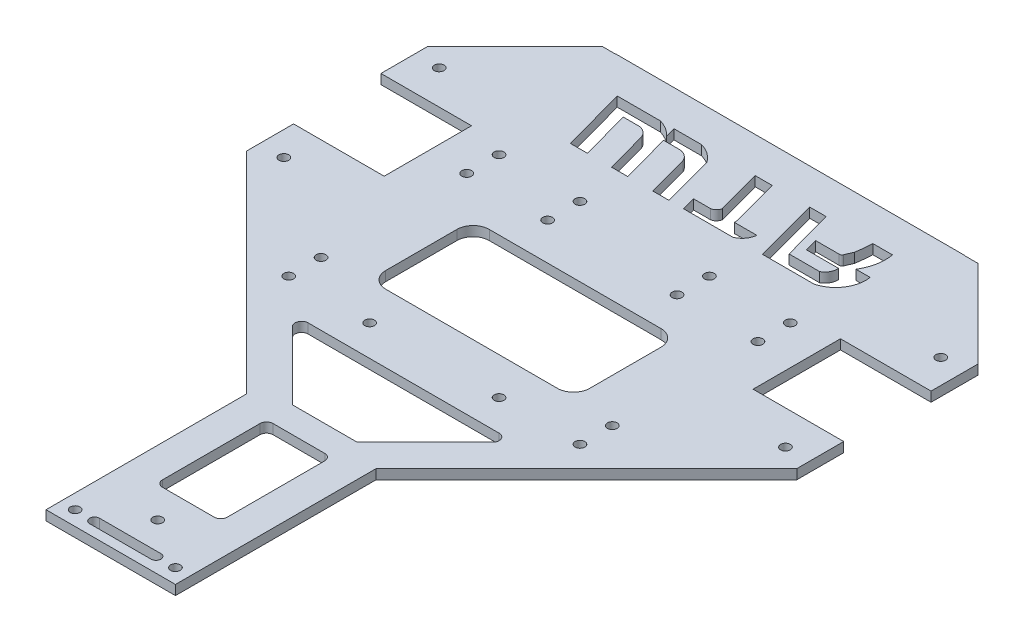
from build123d import *

# Parameters (mm, degrees)
SKETCH_1_R          = 1.5
EXTRUDE_1_DEPTH     = 3
SKETCH_2_R          = 1.5
EXTRUDE_2_DEPTH     = 3
EXTRUDE_6_DEPTH     = 3
CUT_EXTRUDE_1_DEPTH = 3
SKETCH_5_R          = 1.5
CUT_EXTRUDE_2_DEPTH = 3
SKETCH_6_R          = 1.5
CUT_EXTRUDE_5_DEPTH = 3
CUT_EXTRUDE_7_DEPTH = 3
CUT_EXTRUDE_9_DEPTH = 3


with BuildPart() as part:
    # 草图1 → 凸台-拉伸1 (new body)
    with BuildSketch(Plane(origin=(0, 0, 0), x_dir=(1, 0, 0), z_dir=(0, 1, 0))):
        Polygon((58, -55), (85, -28), (85, -13.5), (57, -13.5), (57, 13.5), (85, 13.5), (85, 24), (54, 55), (-54, 55), (-85, 24), (-85, 13.5), (-57, 13.5), (-57, -13.5), (-85, -13.5), (-85, -28), (-58, -55), align=None)
        with Locations((77.5, 24)):
            Circle(SKETCH_1_R, mode=Mode.SUBTRACT)
        with Locations((-77.5, 24)):
            Circle(SKETCH_1_R, mode=Mode.SUBTRACT)
        with Locations((-77.5, -24)):
            Circle(SKETCH_1_R, mode=Mode.SUBTRACT)
        with Locations((77.5, -24)):
            Circle(SKETCH_1_R, mode=Mode.SUBTRACT)
    extrude(amount=EXTRUDE_1_DEPTH)

    # 草图2 → 凸台-拉伸2 (add)
    with BuildSketch(Plane(origin=(0, 3, 0), x_dir=(1, 0, 0), z_dir=(0, 1, 0))):
        Polygon((57, 13.5), (85, 13.5), (85, 24), (54.078462186, 54.921537814), (-54.078462186, 54.921537814), (-85, 24), (-85, 13.5), (-57, 13.5), align=None)
        with Locations((-77.5, 24)):
            Circle(SKETCH_2_R, mode=Mode.SUBTRACT)
        with Locations((77.5, 24)):
            Circle(SKETCH_2_R, mode=Mode.SUBTRACT)
        Polygon((-85, 28), (-85, 24), (-54.078462186, 54.921537814), (-58.078462186, 54.921537814), align=None)
        Polygon((54.078462186, 54.921537814), (85, 24), (85, 28), (58.078462186, 54.921537814), align=None)
    extrude(amount=-EXTRUDE_2_DEPTH)

    # 草图3 → 凸台-拉伸6 (add)
    with BuildSketch(Plane.XZ):
        Polygon((-20, 93), (-20, 87.75862069), (20, 122.24137931), (20, 155), (-20, 155), align=None)
        Polygon((20, 122.24137931), (-20, 87.75862069), (-20, 55), (0, 55), (20, 55), (20, 93), align=None)
        Polygon((58, 55), (20, 93), (20, 55), align=None)
        Polygon((-20, 87.75862069), (-58, 55), (-20, 55), align=None)
        Polygon((-20, 93), (-58, 55), (-20, 87.75862069), align=None)
    extrude(amount=-EXTRUDE_6_DEPTH)

    # 草图4 → 切除-拉伸1 (cut)
    with BuildSketch(Plane.XZ):
        with BuildLine():
            Line((37.877062405, -32.043326777), (27.967198456, -32.043326777))
            Line((27.967198456, -32.043326777), (26.920470281, -35.937088984))
            Line((26.920470281, -35.937088984), (34.10030845, -35.937088984))
            ThreePointArc((34.10030845, -35.937088984), (34.626114104, -36.053786172), (34.982522159, -36.457596916))
            Line((34.982522159, -36.457596916), (36.01321058, -38.838842579))
            ThreePointArc((36.01321058, -38.838842579), (36.340515961, -41.403679155), (36.509138095, -43.983811332))
            Line((36.509138095, -43.983811332), (42.601961842, -43.983811332))
            ThreePointArc((42.601961842, -43.983811332), (42.5762659, -39.074399956), (40.794165727, -34.499785293))
            Line((40.794165727, -34.499785293), (45.17492554, -34.499785293))
            ThreePointArc((45.17492554, -34.499785293), (43.76174943, -27.96012409), (38.337690391, -24.04300539))
            Line((38.337690391, -24.04300539), (22.375875232, -24.04300539))
            Line((22.375875232, -24.04300539), (17.015351834, -43.983811332))
            Line((17.015351834, -43.983811332), (22.13492554, -43.983811332))
            Line((22.13492554, -43.983811332), (26.362036193, -28.259228683))
            Line((26.362036193, -28.259228683), (35.785074012, -28.259228683))
            ThreePointArc((35.785074012, -28.259228683), (37.399599712, -29.836972636), (37.877062405, -32.043326777))
        make_face()
        with BuildLine():
            Line((-11.550995986, -24.04300539), (-14.981294936, -36.803499209))
            ThreePointArc((-14.981294936, -36.803499209), (-16.292875485, -38.4823499), (-18.271581685, -39.271973198))
            Line((-18.271581685, -39.271973198), (-23.446816722, -39.271973198))
            Line((-23.446816722, -39.271973198), (-19.251667099, -24.04300539))
            Line((-19.251667099, -24.04300539), (-24.257103323, -24.04300539))
            Line((-24.257103323, -24.04300539), (-27.772258224, -36.803499209))
            ThreePointArc((-27.772258224, -36.803499209), (-28.982580606, -38.443648962), (-30.845065624, -39.271973198))
            Line((-30.845065624, -39.271973198), (-35.909362481, -39.271973198))
            Line((-35.909362481, -39.271973198), (-31.714212859, -24.04300539))
            Line((-31.714212859, -24.04300539), (-36.98159556, -24.04300539))
            Line((-36.98159556, -24.04300539), (-42.474723235, -43.983811332))
            Line((-42.474723235, -43.983811332), (-29.080521508, -43.983811332))
            ThreePointArc((-29.080521508, -43.983811332), (-26.38947659, -42.772882703), (-24.096572177, -40.915287416))
            Line((-24.096572177, -40.915287416), (-24.941863671, -43.983811332))
            Line((-24.941863671, -43.983811332), (-16.438803025, -43.983811332))
            ThreePointArc((-16.438803025, -43.983811332), (-13.277126117, -42.521672977), (-10.843140715, -40.02973307))
            Line((-10.843140715, -40.02973307), (-6.545559762, -24.04300539))
            Line((-6.545559762, -24.04300539), (-11.550995986, -24.04300539))
        make_face()
        with BuildLine():
            Line((0.178860657, -43.983811332), (3.91734543, -30.076885861))
            ThreePointArc((3.91734543, -30.076885861), (3.312428033, -28.889604932), (2.138466003, -28.259228683))
            Line((2.138466003, -28.259228683), (-3.128615616, -28.259228683))
            Line((-3.128615616, -28.259228683), (-1.99520287, -24.04300539))
            Line((-1.99520287, -24.04300539), (13.155847737, -24.04300539))
            ThreePointArc((13.155847737, -24.04300539), (15.376465747, -25.688977693), (16.393411668, -28.259228683))
            Line((16.393411668, -28.259228683), (9.435065309, -28.259228683))
            Line((9.435065309, -28.259228683), (9.435065309, -29.158996281))
            Line((9.435065309, -29.158996281), (5.449831804, -43.983811332))
            Line((5.449831804, -43.983811332), (0.178860657, -43.983811332))
        make_face()
    extrude(amount=-CUT_EXTRUDE_1_DEPTH, mode=Mode.SUBTRACT)

    # 草图5 → 切除-拉伸2 (cut)
    with BuildSketch(Plane.XZ):
        with Locations((45, 55)):
            Circle(SKETCH_5_R)
        with Locations((-45, 55)):
            Circle(SKETCH_5_R)
        with Locations((20, 55)):
            Circle(SKETCH_5_R)
        with Locations((-20, 55)):
            Circle(SKETCH_5_R)
        with Locations((45, 45)):
            Circle(SKETCH_5_R)
        with Locations((-45, 45)):
            Circle(SKETCH_5_R)
        with Locations((-45, 0)):
            Circle(SKETCH_5_R)
        with Locations((45, 0)):
            Circle(SKETCH_5_R)
        with Locations((45, -10)):
            Circle(SKETCH_5_R)
        with Locations((-45, -10)):
            Circle(SKETCH_5_R)
        with Locations((20, 0)):
            Circle(SKETCH_5_R)
        with Locations((-20, 0)):
            Circle(SKETCH_5_R)
        with Locations((20, -10)):
            Circle(SKETCH_5_R)
        with Locations((-20, -10)):
            Circle(SKETCH_5_R)
    extrude(amount=-CUT_EXTRUDE_2_DEPTH, mode=Mode.SUBTRACT)

    # 草图6 → 切除-拉伸5 (cut)
    with BuildSketch(Plane.XZ):
        with BuildLine():
            Line((0, 150.5), (0, 152))
            Line((0, 152), (-9.5, 152))
            ThreePointArc((-9.5, 152), (-8.439339828, 151.560660172), (-8, 150.5))
            Line((-8, 150.5), (0, 150.5))
        make_face()
        with BuildLine():
            Line((0, 149), (0, 150.5))
            Line((0, 150.5), (-8, 150.5))
            ThreePointArc((-8, 150.5), (-8.439339828, 149.439339828), (-9.5, 149))
            Line((-9.5, 149), (0, 149))
        make_face()
        with BuildLine():
            ThreePointArc((-8, 150.5), (-8.439339828, 151.560660172), (-9.5, 152))
            ThreePointArc((-9.5, 152), (-10.560660172, 151.560660172), (-11, 150.5))
            Line((-11, 150.5), (-8, 150.5))
        make_face()
        with BuildLine():
            ThreePointArc((-9.5, 149), (-8.439339828, 149.439339828), (-8, 150.5))
            Line((-8, 150.5), (-11, 150.5))
            ThreePointArc((-11, 150.5), (-10.560660172, 149.439339828), (-9.5, 149))
        make_face()
        with BuildLine():
            Line((9.5, 152), (0, 152))
            Line((0, 152), (0, 150.5))
            Line((0, 150.5), (8, 150.5))
            ThreePointArc((8, 150.5), (8.439339828, 151.560660172), (9.5, 152))
        make_face()
        with BuildLine():
            Line((8, 150.5), (0, 150.5))
            Line((0, 150.5), (0, 149))
            Line((0, 149), (9.5, 149))
            ThreePointArc((9.5, 149), (8.439339828, 149.439339828), (8, 150.5))
        make_face()
        with BuildLine():
            ThreePointArc((11, 150.5), (10.560660172, 151.560660172), (9.5, 152))
            ThreePointArc((9.5, 152), (8.439339828, 151.560660172), (8, 150.5))
            Line((8, 150.5), (9.5, 150.5))
            Line((9.5, 150.5), (11, 150.5))
        make_face()
        with BuildLine():
            Line((9.5, 150.5), (8, 150.5))
            ThreePointArc((8, 150.5), (8.439339828, 149.439339828), (9.5, 149))
            ThreePointArc((9.5, 149), (10.560660172, 149.439339828), (11, 150.5))
            Line((11, 150.5), (9.5, 150.5))
        make_face()
        with Locations((0, 140.5)):
            Circle(SKETCH_6_R)
        with Locations((-15.5, 150.5)):
            Circle(SKETCH_6_R)
        with Locations((15.5, 150.5)):
            Circle(SKETCH_6_R)
    extrude(amount=-CUT_EXTRUDE_5_DEPTH, mode=Mode.SUBTRACT)

    # 草图7 → 切除-拉伸7 (cut)
    with BuildSketch(Plane.XZ):
        with BuildLine():
            ThreePointArc((-8, 131), (-9.414213562, 130.414213562), (-10, 129))
            Line((-10, 129), (-10, 98.857864376))
            ThreePointArc((-10, 98.857864376), (-9.414213562, 97.443650814), (-8, 96.857864376))
            Line((-8, 96.857864376), (8, 96.857864376))
            ThreePointArc((8, 96.857864376), (9.414213562, 97.443650814), (10, 98.857864376))
            Line((10, 98.857864376), (10, 129))
            ThreePointArc((10, 129), (9.414213562, 130.414213562), (8, 131))
            Line((8, 131), (-8, 131))
        make_face()
        with BuildLine():
            Line((10, 88.857864376), (-10, 88.857864376))
            Line((-10, 88.857864376), (-30.943650814, 67.914213562))
            ThreePointArc((-30.943650814, 67.914213562), (-31.377196317, 65.734633135), (-29.529437252, 64.5))
            Line((-29.529437252, 64.5), (29.529437252, 64.5))
            ThreePointArc((29.529437252, 64.5), (31.377196317, 65.734633135), (30.943650814, 67.914213562))
            Line((30.943650814, 67.914213562), (10, 88.857864376))
        make_face()
    extrude(amount=-CUT_EXTRUDE_7_DEPTH, mode=Mode.SUBTRACT)

    # 草图8 → 切除-拉伸9 (cut)
    with BuildSketch(Plane.XZ):
        with BuildLine():
            Line((31.529437252, 38.5), (31.529437252, 16.5))
            ThreePointArc((31.529437252, 16.5), (30.064971157, 12.964466094), (26.529437252, 11.5))
            Line((26.529437252, 11.5), (-26.529437252, 11.5))
            ThreePointArc((-26.529437252, 11.5), (-30.064971157, 12.964466094), (-31.529437252, 16.5))
            Line((-31.529437252, 16.5), (-31.529437252, 38.5))
            ThreePointArc((-31.529437252, 38.5), (-30.064971157, 42.035533906), (-26.529437252, 43.5))
            Line((-26.529437252, 43.5), (26.529437252, 43.5))
            ThreePointArc((26.529437252, 43.5), (30.064971157, 42.035533906), (31.529437252, 38.5))
        make_face()
    extrude(amount=-CUT_EXTRUDE_9_DEPTH, mode=Mode.SUBTRACT)


solid = part.part
